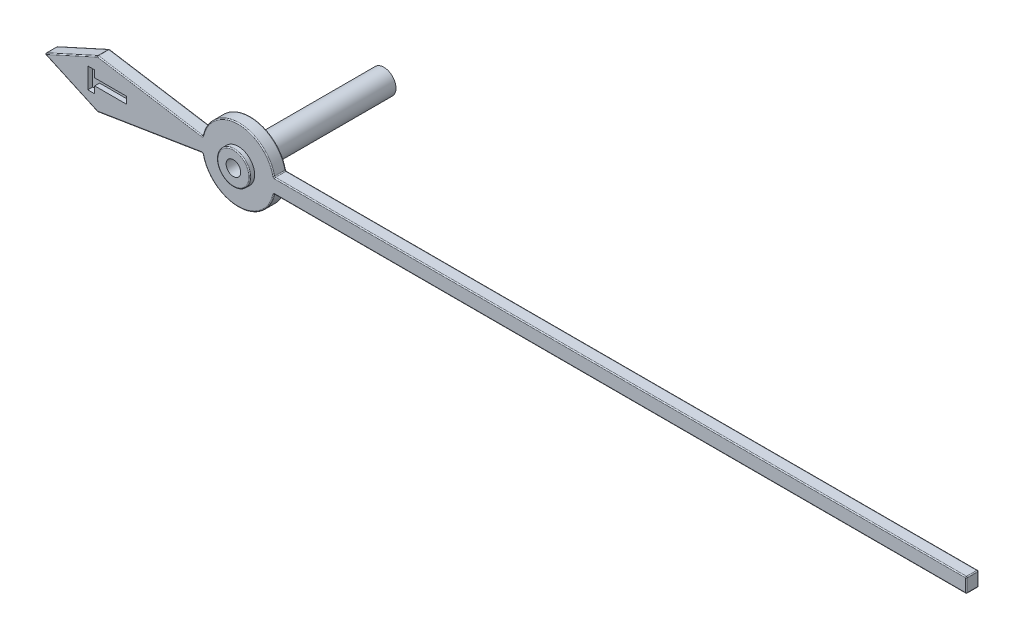
from build123d import *

# Parameters (mm, degrees)
SKETCH1_R           = 0.25
BOSS_EXTRUDE1_DEPTH = 0.25
FILLET1_R           = 0.02
CUT_EXTRUDE1_DEPTH  = 0.1
SKETCH3_R           = 0.338477621
BOSS_EXTRUDE2_DEPTH = 0.1
SKETCH4_R           = 0.25
BOSS_EXTRUDE3_DEPTH = 3
FILLET2_R           = 0.02
SKETCH5_R           = 0.15
CUT_EXTRUDE2_DEPTH  = 0.5


with BuildPart() as part:
    # Sketch1 → Boss-Extrude1 (new body)
    with BuildSketch(Plane.XY):
        with BuildLine():
            Line((15, 0.15), (15, -0.15))
            Line((15, -0.15), (0.734846923, -0.15))
            ThreePointArc((0.734846923, -0.15), (0, -0.75), (-0.734846923, -0.15))
            Line((-0.734846923, -0.15), (-2.9, -0.5))
            Line((-2.9, -0.5), (-4, 0))
            Line((-4, 0), (-2.9, 0.5))
            Line((-2.9, 0.5), (-0.734846923, 0.15))
            ThreePointArc((-0.734846923, 0.15), (0, 0.75), (0.734846923, 0.15))
            Line((0.734846923, 0.15), (15, 0.15))
        make_face()
        Circle(SKETCH1_R, mode=Mode.SUBTRACT)
    extrude(amount=BOSS_EXTRUDE1_DEPTH)

    # Fillet1
    fillet1_edges = [part.edges().sort_by_distance(p)[0] for p in [
        (0, -0.75, 0.25),
        (15, 0, 0),
        (7.867423461, -0.15, 0),
        (0, -0.75, 0),
        (-1.817423461, -0.325, 0),
        (-3.45, -0.25, 0),
        (7.867423461, -0.15, 0.25),
        (-4, 0, 0.125),
        (-2.9, 0.5, 0.125),
        (-0.734846923, 0.15, 0.125),
        (0.734846923, 0.15, 0.125),
        (15, 0.15, 0.125),
        (15, -0.15, 0.125),
        (0.734846923, -0.15, 0.125),
        (-0.734846923, -0.15, 0.125),
        (-2.9, -0.5, 0.125),
        (15, 0, 0.25),
        (7.867423461, 0.15, 0.25),
        (0, 0.75, 0.25),
        (-0.25, 0, 0),
        (-0.25, 0, 0.25),
        (-1.817423461, 0.325, 0.25),
        (-3.45, 0.25, 0.25),
        (-3.45, -0.25, 0.25),
        (-1.817423461, -0.325, 0.25),
        (-3.45, 0.25, 0),
        (-1.817423461, 0.325, 0),
        (0, 0.75, 0),
        (7.867423461, 0.15, 0),
    ]]
    fillet(fillet1_edges, radius=FILLET1_R)

    # Sketch2 → Cut-Extrude1 (cut)
    with BuildSketch(Plane.XY.offset(0.25)):
        Polygon((-3.098977029, -0.203794583), (-3.098977029, 0.223609263), (-2.95650908, 0.223609263), (-2.95650908, 0.081141314), (-2.305227029, 0.081141314), (-2.305227029, -0.061326635), (-2.95650908, -0.061326635), (-2.95650908, -0.203794583), align=None)
    extrude(amount=-CUT_EXTRUDE1_DEPTH, mode=Mode.SUBTRACT)

    # Sketch3 → Boss-Extrude2 (add)
    with BuildSketch(Plane.XY.offset(0.25)):
        Circle(SKETCH3_R)
    extrude(amount=BOSS_EXTRUDE2_DEPTH)

    # Sketch4 → Boss-Extrude3 (add)
    with BuildSketch(Plane(origin=(0, 0, 0.25), x_dir=(-1, 0, 0), z_dir=(0, 0, -1))):
        Circle(SKETCH4_R)
    extrude(amount=BOSS_EXTRUDE3_DEPTH)

    # Fillet2
    fillet2_edges = [part.edges().sort_by_distance(p)[0] for p in [
        (-0.338477621, 0, 0.35),
    ]]
    fillet(fillet2_edges, radius=FILLET2_R)

    # Sketch5 → Cut-Extrude2 (cut)
    with BuildSketch(Plane.XY.offset(0.35)):
        Circle(SKETCH5_R)
    extrude(amount=-CUT_EXTRUDE2_DEPTH, mode=Mode.SUBTRACT)


solid = part.part
